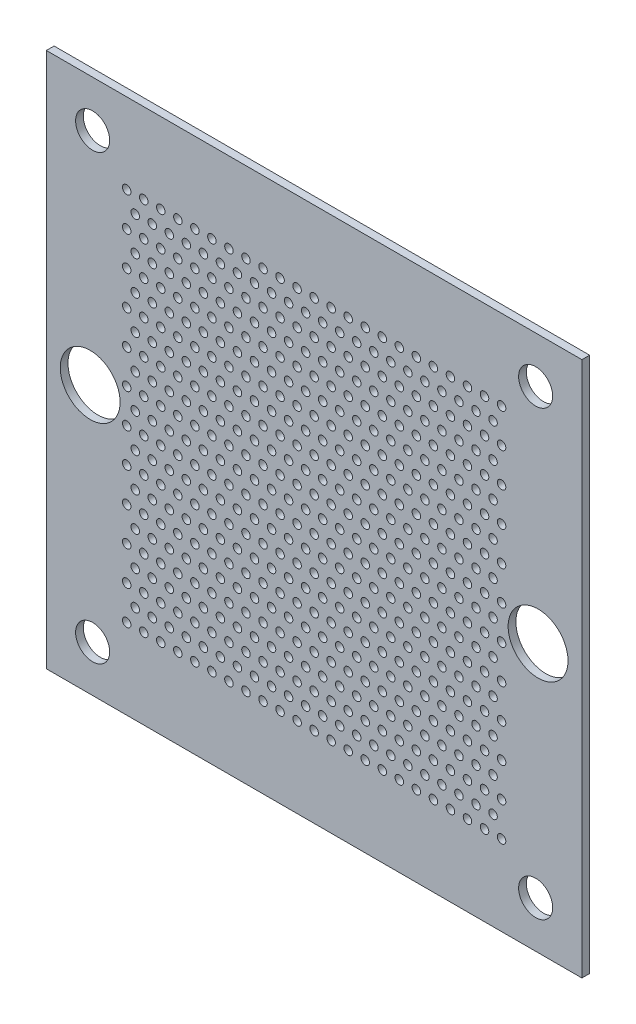
from build123d import *

# Parameters (mm, degrees)
MODEL_W             = 110
MODEL_H             = 110
MODEL_R             = 3.5
MODEL_R_2           = 0.875
MODEL_R_3           = 6.15
BOSS_EXTRUDE1_DEPTH = 1.5875


with BuildPart() as part:
    # Model → Boss-Extrude1 (new body)
    with BuildSketch(Plane.XY):
        with Locations((38.5, 38.5)):
            Rectangle(MODEL_W, MODEL_H)
        with Locations((84, 84)):
            Circle(MODEL_R, mode=Mode.SUBTRACT)
        with Locations((-7, 84)):
            Circle(MODEL_R, mode=Mode.SUBTRACT)
        with Locations((-7, -7)):
            Circle(MODEL_R, mode=Mode.SUBTRACT)
        with Locations((84, -7)):
            Circle(MODEL_R, mode=Mode.SUBTRACT)
        with Locations((77, 0)):
            Circle(MODEL_R_2, mode=Mode.SUBTRACT)
        with Locations((73.5, 0)):
            Circle(MODEL_R_2, mode=Mode.SUBTRACT)
        with Locations((70, 0)):
            Circle(MODEL_R_2, mode=Mode.SUBTRACT)
        with Locations((66.5, 0)):
            Circle(MODEL_R_2, mode=Mode.SUBTRACT)
        with Locations((63, 0)):
            Circle(MODEL_R_2, mode=Mode.SUBTRACT)
        with Locations((59.5, 0)):
            Circle(MODEL_R_2, mode=Mode.SUBTRACT)
        with Locations((56, 0)):
            Circle(MODEL_R_2, mode=Mode.SUBTRACT)
        with Locations((52.5, 0)):
            Circle(MODEL_R_2, mode=Mode.SUBTRACT)
        with Locations((49, 0)):
            Circle(MODEL_R_2, mode=Mode.SUBTRACT)
        with Locations((45.5, 0)):
            Circle(MODEL_R_2, mode=Mode.SUBTRACT)
        with Locations((42, 0)):
            Circle(MODEL_R_2, mode=Mode.SUBTRACT)
        with Locations((38.5, 0)):
            Circle(MODEL_R_2, mode=Mode.SUBTRACT)
        with Locations((35, 0)):
            Circle(MODEL_R_2, mode=Mode.SUBTRACT)
        with Locations((31.5, 0)):
            Circle(MODEL_R_2, mode=Mode.SUBTRACT)
        with Locations((28, 0)):
            Circle(MODEL_R_2, mode=Mode.SUBTRACT)
        with Locations((24.5, 0)):
            Circle(MODEL_R_2, mode=Mode.SUBTRACT)
        with Locations((21, 0)):
            Circle(MODEL_R_2, mode=Mode.SUBTRACT)
        with Locations((17.5, 0)):
            Circle(MODEL_R_2, mode=Mode.SUBTRACT)
        with Locations((14, 0)):
            Circle(MODEL_R_2, mode=Mode.SUBTRACT)
        with Locations((10.5, 0)):
            Circle(MODEL_R_2, mode=Mode.SUBTRACT)
        with Locations((7, 0)):
            Circle(MODEL_R_2, mode=Mode.SUBTRACT)
        with Locations((3.5, 0)):
            Circle(MODEL_R_2, mode=Mode.SUBTRACT)
        Circle(MODEL_R_2, mode=Mode.SUBTRACT)
        with Locations((75.25, 3.5)):
            Circle(MODEL_R_2, mode=Mode.SUBTRACT)
        with Locations((71.75, 3.5)):
            Circle(MODEL_R_2, mode=Mode.SUBTRACT)
        with Locations((68.25, 3.5)):
            Circle(MODEL_R_2, mode=Mode.SUBTRACT)
        with Locations((64.75, 3.5)):
            Circle(MODEL_R_2, mode=Mode.SUBTRACT)
        with Locations((61.25, 3.5)):
            Circle(MODEL_R_2, mode=Mode.SUBTRACT)
        with Locations((57.75, 3.5)):
            Circle(MODEL_R_2, mode=Mode.SUBTRACT)
        with Locations((54.25, 3.5)):
            Circle(MODEL_R_2, mode=Mode.SUBTRACT)
        with Locations((50.75, 3.5)):
            Circle(MODEL_R_2, mode=Mode.SUBTRACT)
        with Locations((47.25, 3.5)):
            Circle(MODEL_R_2, mode=Mode.SUBTRACT)
        with Locations((43.75, 3.5)):
            Circle(MODEL_R_2, mode=Mode.SUBTRACT)
        with Locations((40.25, 3.5)):
            Circle(MODEL_R_2, mode=Mode.SUBTRACT)
        with Locations((36.75, 3.5)):
            Circle(MODEL_R_2, mode=Mode.SUBTRACT)
        with Locations((33.25, 3.5)):
            Circle(MODEL_R_2, mode=Mode.SUBTRACT)
        with Locations((29.75, 3.5)):
            Circle(MODEL_R_2, mode=Mode.SUBTRACT)
        with Locations((26.25, 3.5)):
            Circle(MODEL_R_2, mode=Mode.SUBTRACT)
        with Locations((22.75, 3.5)):
            Circle(MODEL_R_2, mode=Mode.SUBTRACT)
        with Locations((19.25, 3.5)):
            Circle(MODEL_R_2, mode=Mode.SUBTRACT)
        with Locations((15.75, 3.5)):
            Circle(MODEL_R_2, mode=Mode.SUBTRACT)
        with Locations((12.25, 3.5)):
            Circle(MODEL_R_2, mode=Mode.SUBTRACT)
        with Locations((8.75, 3.5)):
            Circle(MODEL_R_2, mode=Mode.SUBTRACT)
        with Locations((5.25, 3.5)):
            Circle(MODEL_R_2, mode=Mode.SUBTRACT)
        with Locations((1.75, 3.5)):
            Circle(MODEL_R_2, mode=Mode.SUBTRACT)
        with Locations((77, 7)):
            Circle(MODEL_R_2, mode=Mode.SUBTRACT)
        with Locations((73.5, 7)):
            Circle(MODEL_R_2, mode=Mode.SUBTRACT)
        with Locations((70, 7)):
            Circle(MODEL_R_2, mode=Mode.SUBTRACT)
        with Locations((66.5, 7)):
            Circle(MODEL_R_2, mode=Mode.SUBTRACT)
        with Locations((63, 7)):
            Circle(MODEL_R_2, mode=Mode.SUBTRACT)
        with Locations((59.5, 7)):
            Circle(MODEL_R_2, mode=Mode.SUBTRACT)
        with Locations((56, 7)):
            Circle(MODEL_R_2, mode=Mode.SUBTRACT)
        with Locations((52.5, 7)):
            Circle(MODEL_R_2, mode=Mode.SUBTRACT)
        with Locations((49, 7)):
            Circle(MODEL_R_2, mode=Mode.SUBTRACT)
        with Locations((45.5, 7)):
            Circle(MODEL_R_2, mode=Mode.SUBTRACT)
        with Locations((42, 7)):
            Circle(MODEL_R_2, mode=Mode.SUBTRACT)
        with Locations((38.5, 7)):
            Circle(MODEL_R_2, mode=Mode.SUBTRACT)
        with Locations((35, 7)):
            Circle(MODEL_R_2, mode=Mode.SUBTRACT)
        with Locations((31.5, 7)):
            Circle(MODEL_R_2, mode=Mode.SUBTRACT)
        with Locations((28, 7)):
            Circle(MODEL_R_2, mode=Mode.SUBTRACT)
        with Locations((24.5, 7)):
            Circle(MODEL_R_2, mode=Mode.SUBTRACT)
        with Locations((21, 7)):
            Circle(MODEL_R_2, mode=Mode.SUBTRACT)
        with Locations((17.5, 7)):
            Circle(MODEL_R_2, mode=Mode.SUBTRACT)
        with Locations((14, 7)):
            Circle(MODEL_R_2, mode=Mode.SUBTRACT)
        with Locations((10.5, 7)):
            Circle(MODEL_R_2, mode=Mode.SUBTRACT)
        with Locations((7, 7)):
            Circle(MODEL_R_2, mode=Mode.SUBTRACT)
        with Locations((3.5, 7)):
            Circle(MODEL_R_2, mode=Mode.SUBTRACT)
        with Locations((0, 7)):
            Circle(MODEL_R_2, mode=Mode.SUBTRACT)
        with Locations((75.25, 10.5)):
            Circle(MODEL_R_2, mode=Mode.SUBTRACT)
        with Locations((71.75, 10.5)):
            Circle(MODEL_R_2, mode=Mode.SUBTRACT)
        with Locations((68.25, 10.5)):
            Circle(MODEL_R_2, mode=Mode.SUBTRACT)
        with Locations((64.75, 10.5)):
            Circle(MODEL_R_2, mode=Mode.SUBTRACT)
        with Locations((61.25, 10.5)):
            Circle(MODEL_R_2, mode=Mode.SUBTRACT)
        with Locations((57.75, 10.5)):
            Circle(MODEL_R_2, mode=Mode.SUBTRACT)
        with Locations((54.25, 10.5)):
            Circle(MODEL_R_2, mode=Mode.SUBTRACT)
        with Locations((50.75, 10.5)):
            Circle(MODEL_R_2, mode=Mode.SUBTRACT)
        with Locations((47.25, 10.5)):
            Circle(MODEL_R_2, mode=Mode.SUBTRACT)
        with Locations((43.75, 10.5)):
            Circle(MODEL_R_2, mode=Mode.SUBTRACT)
        with Locations((40.25, 10.5)):
            Circle(MODEL_R_2, mode=Mode.SUBTRACT)
        with Locations((36.75, 10.5)):
            Circle(MODEL_R_2, mode=Mode.SUBTRACT)
        with Locations((33.25, 10.5)):
            Circle(MODEL_R_2, mode=Mode.SUBTRACT)
        with Locations((29.75, 10.5)):
            Circle(MODEL_R_2, mode=Mode.SUBTRACT)
        with Locations((26.25, 10.5)):
            Circle(MODEL_R_2, mode=Mode.SUBTRACT)
        with Locations((22.75, 10.5)):
            Circle(MODEL_R_2, mode=Mode.SUBTRACT)
        with Locations((19.25, 10.5)):
            Circle(MODEL_R_2, mode=Mode.SUBTRACT)
        with Locations((15.75, 10.5)):
            Circle(MODEL_R_2, mode=Mode.SUBTRACT)
        with Locations((12.25, 10.5)):
            Circle(MODEL_R_2, mode=Mode.SUBTRACT)
        with Locations((8.75, 10.5)):
            Circle(MODEL_R_2, mode=Mode.SUBTRACT)
        with Locations((5.25, 10.5)):
            Circle(MODEL_R_2, mode=Mode.SUBTRACT)
        with Locations((1.75, 10.5)):
            Circle(MODEL_R_2, mode=Mode.SUBTRACT)
        with Locations((77, 14)):
            Circle(MODEL_R_2, mode=Mode.SUBTRACT)
        with Locations((73.5, 14)):
            Circle(MODEL_R_2, mode=Mode.SUBTRACT)
        with Locations((70, 14)):
            Circle(MODEL_R_2, mode=Mode.SUBTRACT)
        with Locations((66.5, 14)):
            Circle(MODEL_R_2, mode=Mode.SUBTRACT)
        with Locations((63, 14)):
            Circle(MODEL_R_2, mode=Mode.SUBTRACT)
        with Locations((59.5, 14)):
            Circle(MODEL_R_2, mode=Mode.SUBTRACT)
        with Locations((56, 14)):
            Circle(MODEL_R_2, mode=Mode.SUBTRACT)
        with Locations((52.5, 14)):
            Circle(MODEL_R_2, mode=Mode.SUBTRACT)
        with Locations((49, 14)):
            Circle(MODEL_R_2, mode=Mode.SUBTRACT)
        with Locations((45.5, 14)):
            Circle(MODEL_R_2, mode=Mode.SUBTRACT)
        with Locations((42, 14)):
            Circle(MODEL_R_2, mode=Mode.SUBTRACT)
        with Locations((38.5, 14)):
            Circle(MODEL_R_2, mode=Mode.SUBTRACT)
        with Locations((35, 14)):
            Circle(MODEL_R_2, mode=Mode.SUBTRACT)
        with Locations((31.5, 14)):
            Circle(MODEL_R_2, mode=Mode.SUBTRACT)
        with Locations((28, 14)):
            Circle(MODEL_R_2, mode=Mode.SUBTRACT)
        with Locations((24.5, 14)):
            Circle(MODEL_R_2, mode=Mode.SUBTRACT)
        with Locations((21, 14)):
            Circle(MODEL_R_2, mode=Mode.SUBTRACT)
        with Locations((17.5, 14)):
            Circle(MODEL_R_2, mode=Mode.SUBTRACT)
        with Locations((14, 14)):
            Circle(MODEL_R_2, mode=Mode.SUBTRACT)
        with Locations((10.5, 14)):
            Circle(MODEL_R_2, mode=Mode.SUBTRACT)
        with Locations((7, 14)):
            Circle(MODEL_R_2, mode=Mode.SUBTRACT)
        with Locations((3.5, 14)):
            Circle(MODEL_R_2, mode=Mode.SUBTRACT)
        with Locations((0, 14)):
            Circle(MODEL_R_2, mode=Mode.SUBTRACT)
        with Locations((75.25, 17.5)):
            Circle(MODEL_R_2, mode=Mode.SUBTRACT)
        with Locations((71.75, 17.5)):
            Circle(MODEL_R_2, mode=Mode.SUBTRACT)
        with Locations((68.25, 17.5)):
            Circle(MODEL_R_2, mode=Mode.SUBTRACT)
        with Locations((64.75, 17.5)):
            Circle(MODEL_R_2, mode=Mode.SUBTRACT)
        with Locations((61.25, 17.5)):
            Circle(MODEL_R_2, mode=Mode.SUBTRACT)
        with Locations((57.75, 17.5)):
            Circle(MODEL_R_2, mode=Mode.SUBTRACT)
        with Locations((54.25, 17.5)):
            Circle(MODEL_R_2, mode=Mode.SUBTRACT)
        with Locations((50.75, 17.5)):
            Circle(MODEL_R_2, mode=Mode.SUBTRACT)
        with Locations((47.25, 17.5)):
            Circle(MODEL_R_2, mode=Mode.SUBTRACT)
        with Locations((43.75, 17.5)):
            Circle(MODEL_R_2, mode=Mode.SUBTRACT)
        with Locations((40.25, 17.5)):
            Circle(MODEL_R_2, mode=Mode.SUBTRACT)
        with Locations((36.75, 17.5)):
            Circle(MODEL_R_2, mode=Mode.SUBTRACT)
        with Locations((33.25, 17.5)):
            Circle(MODEL_R_2, mode=Mode.SUBTRACT)
        with Locations((29.75, 17.5)):
            Circle(MODEL_R_2, mode=Mode.SUBTRACT)
        with Locations((26.25, 17.5)):
            Circle(MODEL_R_2, mode=Mode.SUBTRACT)
        with Locations((22.75, 17.5)):
            Circle(MODEL_R_2, mode=Mode.SUBTRACT)
        with Locations((19.25, 17.5)):
            Circle(MODEL_R_2, mode=Mode.SUBTRACT)
        with Locations((15.75, 17.5)):
            Circle(MODEL_R_2, mode=Mode.SUBTRACT)
        with Locations((12.25, 17.5)):
            Circle(MODEL_R_2, mode=Mode.SUBTRACT)
        with Locations((8.75, 17.5)):
            Circle(MODEL_R_2, mode=Mode.SUBTRACT)
        with Locations((5.25, 17.5)):
            Circle(MODEL_R_2, mode=Mode.SUBTRACT)
        with Locations((1.75, 17.5)):
            Circle(MODEL_R_2, mode=Mode.SUBTRACT)
        with Locations((77, 21)):
            Circle(MODEL_R_2, mode=Mode.SUBTRACT)
        with Locations((73.5, 21)):
            Circle(MODEL_R_2, mode=Mode.SUBTRACT)
        with Locations((70, 21)):
            Circle(MODEL_R_2, mode=Mode.SUBTRACT)
        with Locations((66.5, 21)):
            Circle(MODEL_R_2, mode=Mode.SUBTRACT)
        with Locations((63, 21)):
            Circle(MODEL_R_2, mode=Mode.SUBTRACT)
        with Locations((59.5, 21)):
            Circle(MODEL_R_2, mode=Mode.SUBTRACT)
        with Locations((56, 21)):
            Circle(MODEL_R_2, mode=Mode.SUBTRACT)
        with Locations((52.5, 21)):
            Circle(MODEL_R_2, mode=Mode.SUBTRACT)
        with Locations((49, 21)):
            Circle(MODEL_R_2, mode=Mode.SUBTRACT)
        with Locations((45.5, 21)):
            Circle(MODEL_R_2, mode=Mode.SUBTRACT)
        with Locations((42, 21)):
            Circle(MODEL_R_2, mode=Mode.SUBTRACT)
        with Locations((38.5, 21)):
            Circle(MODEL_R_2, mode=Mode.SUBTRACT)
        with Locations((35, 21)):
            Circle(MODEL_R_2, mode=Mode.SUBTRACT)
        with Locations((31.5, 21)):
            Circle(MODEL_R_2, mode=Mode.SUBTRACT)
        with Locations((28, 21)):
            Circle(MODEL_R_2, mode=Mode.SUBTRACT)
        with Locations((24.5, 21)):
            Circle(MODEL_R_2, mode=Mode.SUBTRACT)
        with Locations((21, 21)):
            Circle(MODEL_R_2, mode=Mode.SUBTRACT)
        with Locations((17.5, 21)):
            Circle(MODEL_R_2, mode=Mode.SUBTRACT)
        with Locations((14, 21)):
            Circle(MODEL_R_2, mode=Mode.SUBTRACT)
        with Locations((10.5, 21)):
            Circle(MODEL_R_2, mode=Mode.SUBTRACT)
        with Locations((7, 21)):
            Circle(MODEL_R_2, mode=Mode.SUBTRACT)
        with Locations((3.5, 21)):
            Circle(MODEL_R_2, mode=Mode.SUBTRACT)
        with Locations((0, 21)):
            Circle(MODEL_R_2, mode=Mode.SUBTRACT)
        with Locations((75.25, 24.5)):
            Circle(MODEL_R_2, mode=Mode.SUBTRACT)
        with Locations((71.75, 24.5)):
            Circle(MODEL_R_2, mode=Mode.SUBTRACT)
        with Locations((68.25, 24.5)):
            Circle(MODEL_R_2, mode=Mode.SUBTRACT)
        with Locations((64.75, 24.5)):
            Circle(MODEL_R_2, mode=Mode.SUBTRACT)
        with Locations((61.25, 24.5)):
            Circle(MODEL_R_2, mode=Mode.SUBTRACT)
        with Locations((57.75, 24.5)):
            Circle(MODEL_R_2, mode=Mode.SUBTRACT)
        with Locations((54.25, 24.5)):
            Circle(MODEL_R_2, mode=Mode.SUBTRACT)
        with Locations((50.75, 24.5)):
            Circle(MODEL_R_2, mode=Mode.SUBTRACT)
        with Locations((47.25, 24.5)):
            Circle(MODEL_R_2, mode=Mode.SUBTRACT)
        with Locations((43.75, 24.5)):
            Circle(MODEL_R_2, mode=Mode.SUBTRACT)
        with Locations((40.25, 24.5)):
            Circle(MODEL_R_2, mode=Mode.SUBTRACT)
        with Locations((36.75, 24.5)):
            Circle(MODEL_R_2, mode=Mode.SUBTRACT)
        with Locations((33.25, 24.5)):
            Circle(MODEL_R_2, mode=Mode.SUBTRACT)
        with Locations((29.75, 24.5)):
            Circle(MODEL_R_2, mode=Mode.SUBTRACT)
        with Locations((26.25, 24.5)):
            Circle(MODEL_R_2, mode=Mode.SUBTRACT)
        with Locations((22.75, 24.5)):
            Circle(MODEL_R_2, mode=Mode.SUBTRACT)
        with Locations((19.25, 24.5)):
            Circle(MODEL_R_2, mode=Mode.SUBTRACT)
        with Locations((15.75, 24.5)):
            Circle(MODEL_R_2, mode=Mode.SUBTRACT)
        with Locations((12.25, 24.5)):
            Circle(MODEL_R_2, mode=Mode.SUBTRACT)
        with Locations((8.75, 24.5)):
            Circle(MODEL_R_2, mode=Mode.SUBTRACT)
        with Locations((5.25, 24.5)):
            Circle(MODEL_R_2, mode=Mode.SUBTRACT)
        with Locations((1.75, 24.5)):
            Circle(MODEL_R_2, mode=Mode.SUBTRACT)
        with Locations((77, 28)):
            Circle(MODEL_R_2, mode=Mode.SUBTRACT)
        with Locations((73.5, 28)):
            Circle(MODEL_R_2, mode=Mode.SUBTRACT)
        with Locations((70, 28)):
            Circle(MODEL_R_2, mode=Mode.SUBTRACT)
        with Locations((66.5, 28)):
            Circle(MODEL_R_2, mode=Mode.SUBTRACT)
        with Locations((63, 28)):
            Circle(MODEL_R_2, mode=Mode.SUBTRACT)
        with Locations((59.5, 28)):
            Circle(MODEL_R_2, mode=Mode.SUBTRACT)
        with Locations((56, 28)):
            Circle(MODEL_R_2, mode=Mode.SUBTRACT)
        with Locations((52.5, 28)):
            Circle(MODEL_R_2, mode=Mode.SUBTRACT)
        with Locations((49, 28)):
            Circle(MODEL_R_2, mode=Mode.SUBTRACT)
        with Locations((45.5, 28)):
            Circle(MODEL_R_2, mode=Mode.SUBTRACT)
        with Locations((42, 28)):
            Circle(MODEL_R_2, mode=Mode.SUBTRACT)
        with Locations((38.5, 28)):
            Circle(MODEL_R_2, mode=Mode.SUBTRACT)
        with Locations((35, 28)):
            Circle(MODEL_R_2, mode=Mode.SUBTRACT)
        with Locations((31.5, 28)):
            Circle(MODEL_R_2, mode=Mode.SUBTRACT)
        with Locations((28, 28)):
            Circle(MODEL_R_2, mode=Mode.SUBTRACT)
        with Locations((24.5, 28)):
            Circle(MODEL_R_2, mode=Mode.SUBTRACT)
        with Locations((21, 28)):
            Circle(MODEL_R_2, mode=Mode.SUBTRACT)
        with Locations((17.5, 28)):
            Circle(MODEL_R_2, mode=Mode.SUBTRACT)
        with Locations((14, 28)):
            Circle(MODEL_R_2, mode=Mode.SUBTRACT)
        with Locations((10.5, 28)):
            Circle(MODEL_R_2, mode=Mode.SUBTRACT)
        with Locations((7, 28)):
            Circle(MODEL_R_2, mode=Mode.SUBTRACT)
        with Locations((3.5, 28)):
            Circle(MODEL_R_2, mode=Mode.SUBTRACT)
        with Locations((0, 28)):
            Circle(MODEL_R_2, mode=Mode.SUBTRACT)
        with Locations((75.25, 31.5)):
            Circle(MODEL_R_2, mode=Mode.SUBTRACT)
        with Locations((71.75, 31.5)):
            Circle(MODEL_R_2, mode=Mode.SUBTRACT)
        with Locations((68.25, 31.5)):
            Circle(MODEL_R_2, mode=Mode.SUBTRACT)
        with Locations((64.75, 31.5)):
            Circle(MODEL_R_2, mode=Mode.SUBTRACT)
        with Locations((61.25, 31.5)):
            Circle(MODEL_R_2, mode=Mode.SUBTRACT)
        with Locations((57.75, 31.5)):
            Circle(MODEL_R_2, mode=Mode.SUBTRACT)
        with Locations((54.25, 31.5)):
            Circle(MODEL_R_2, mode=Mode.SUBTRACT)
        with Locations((50.75, 31.5)):
            Circle(MODEL_R_2, mode=Mode.SUBTRACT)
        with Locations((47.25, 31.5)):
            Circle(MODEL_R_2, mode=Mode.SUBTRACT)
        with Locations((43.75, 31.5)):
            Circle(MODEL_R_2, mode=Mode.SUBTRACT)
        with Locations((40.25, 31.5)):
            Circle(MODEL_R_2, mode=Mode.SUBTRACT)
        with Locations((36.75, 31.5)):
            Circle(MODEL_R_2, mode=Mode.SUBTRACT)
        with Locations((33.25, 31.5)):
            Circle(MODEL_R_2, mode=Mode.SUBTRACT)
        with Locations((29.75, 31.5)):
            Circle(MODEL_R_2, mode=Mode.SUBTRACT)
        with Locations((26.25, 31.5)):
            Circle(MODEL_R_2, mode=Mode.SUBTRACT)
        with Locations((22.75, 31.5)):
            Circle(MODEL_R_2, mode=Mode.SUBTRACT)
        with Locations((19.25, 31.5)):
            Circle(MODEL_R_2, mode=Mode.SUBTRACT)
        with Locations((15.75, 31.5)):
            Circle(MODEL_R_2, mode=Mode.SUBTRACT)
        with Locations((12.25, 31.5)):
            Circle(MODEL_R_2, mode=Mode.SUBTRACT)
        with Locations((8.75, 31.5)):
            Circle(MODEL_R_2, mode=Mode.SUBTRACT)
        with Locations((5.25, 31.5)):
            Circle(MODEL_R_2, mode=Mode.SUBTRACT)
        with Locations((1.75, 31.5)):
            Circle(MODEL_R_2, mode=Mode.SUBTRACT)
        with Locations((77, 35)):
            Circle(MODEL_R_2, mode=Mode.SUBTRACT)
        with Locations((73.5, 35)):
            Circle(MODEL_R_2, mode=Mode.SUBTRACT)
        with Locations((70, 35)):
            Circle(MODEL_R_2, mode=Mode.SUBTRACT)
        with Locations((66.5, 35)):
            Circle(MODEL_R_2, mode=Mode.SUBTRACT)
        with Locations((63, 35)):
            Circle(MODEL_R_2, mode=Mode.SUBTRACT)
        with Locations((59.5, 35)):
            Circle(MODEL_R_2, mode=Mode.SUBTRACT)
        with Locations((56, 35)):
            Circle(MODEL_R_2, mode=Mode.SUBTRACT)
        with Locations((52.5, 35)):
            Circle(MODEL_R_2, mode=Mode.SUBTRACT)
        with Locations((49, 35)):
            Circle(MODEL_R_2, mode=Mode.SUBTRACT)
        with Locations((45.5, 35)):
            Circle(MODEL_R_2, mode=Mode.SUBTRACT)
        with Locations((42, 35)):
            Circle(MODEL_R_2, mode=Mode.SUBTRACT)
        with Locations((38.5, 35)):
            Circle(MODEL_R_2, mode=Mode.SUBTRACT)
        with Locations((35, 35)):
            Circle(MODEL_R_2, mode=Mode.SUBTRACT)
        with Locations((31.5, 35)):
            Circle(MODEL_R_2, mode=Mode.SUBTRACT)
        with Locations((28, 35)):
            Circle(MODEL_R_2, mode=Mode.SUBTRACT)
        with Locations((24.5, 35)):
            Circle(MODEL_R_2, mode=Mode.SUBTRACT)
        with Locations((21, 35)):
            Circle(MODEL_R_2, mode=Mode.SUBTRACT)
        with Locations((17.5, 35)):
            Circle(MODEL_R_2, mode=Mode.SUBTRACT)
        with Locations((14, 35)):
            Circle(MODEL_R_2, mode=Mode.SUBTRACT)
        with Locations((10.5, 35)):
            Circle(MODEL_R_2, mode=Mode.SUBTRACT)
        with Locations((7, 35)):
            Circle(MODEL_R_2, mode=Mode.SUBTRACT)
        with Locations((3.5, 35)):
            Circle(MODEL_R_2, mode=Mode.SUBTRACT)
        with Locations((0, 35)):
            Circle(MODEL_R_2, mode=Mode.SUBTRACT)
        with Locations((75.25, 38.5)):
            Circle(MODEL_R_2, mode=Mode.SUBTRACT)
        with Locations((71.75, 38.5)):
            Circle(MODEL_R_2, mode=Mode.SUBTRACT)
        with Locations((68.25, 38.5)):
            Circle(MODEL_R_2, mode=Mode.SUBTRACT)
        with Locations((64.75, 38.5)):
            Circle(MODEL_R_2, mode=Mode.SUBTRACT)
        with Locations((61.25, 38.5)):
            Circle(MODEL_R_2, mode=Mode.SUBTRACT)
        with Locations((57.75, 38.5)):
            Circle(MODEL_R_2, mode=Mode.SUBTRACT)
        with Locations((54.25, 38.5)):
            Circle(MODEL_R_2, mode=Mode.SUBTRACT)
        with Locations((50.75, 38.5)):
            Circle(MODEL_R_2, mode=Mode.SUBTRACT)
        with Locations((47.25, 38.5)):
            Circle(MODEL_R_2, mode=Mode.SUBTRACT)
        with Locations((43.75, 38.5)):
            Circle(MODEL_R_2, mode=Mode.SUBTRACT)
        with Locations((40.25, 38.5)):
            Circle(MODEL_R_2, mode=Mode.SUBTRACT)
        with Locations((36.75, 38.5)):
            Circle(MODEL_R_2, mode=Mode.SUBTRACT)
        with Locations((33.25, 38.5)):
            Circle(MODEL_R_2, mode=Mode.SUBTRACT)
        with Locations((29.75, 38.5)):
            Circle(MODEL_R_2, mode=Mode.SUBTRACT)
        with Locations((26.25, 38.5)):
            Circle(MODEL_R_2, mode=Mode.SUBTRACT)
        with Locations((22.75, 38.5)):
            Circle(MODEL_R_2, mode=Mode.SUBTRACT)
        with Locations((19.25, 38.5)):
            Circle(MODEL_R_2, mode=Mode.SUBTRACT)
        with Locations((15.75, 38.5)):
            Circle(MODEL_R_2, mode=Mode.SUBTRACT)
        with Locations((12.25, 38.5)):
            Circle(MODEL_R_2, mode=Mode.SUBTRACT)
        with Locations((8.75, 38.5)):
            Circle(MODEL_R_2, mode=Mode.SUBTRACT)
        with Locations((5.25, 38.5)):
            Circle(MODEL_R_2, mode=Mode.SUBTRACT)
        with Locations((1.75, 38.5)):
            Circle(MODEL_R_2, mode=Mode.SUBTRACT)
        with Locations((77, 42)):
            Circle(MODEL_R_2, mode=Mode.SUBTRACT)
        with Locations((73.5, 42)):
            Circle(MODEL_R_2, mode=Mode.SUBTRACT)
        with Locations((70, 42)):
            Circle(MODEL_R_2, mode=Mode.SUBTRACT)
        with Locations((66.5, 42)):
            Circle(MODEL_R_2, mode=Mode.SUBTRACT)
        with Locations((63, 42)):
            Circle(MODEL_R_2, mode=Mode.SUBTRACT)
        with Locations((59.5, 42)):
            Circle(MODEL_R_2, mode=Mode.SUBTRACT)
        with Locations((56, 42)):
            Circle(MODEL_R_2, mode=Mode.SUBTRACT)
        with Locations((52.5, 42)):
            Circle(MODEL_R_2, mode=Mode.SUBTRACT)
        with Locations((49, 42)):
            Circle(MODEL_R_2, mode=Mode.SUBTRACT)
        with Locations((45.5, 42)):
            Circle(MODEL_R_2, mode=Mode.SUBTRACT)
        with Locations((42, 42)):
            Circle(MODEL_R_2, mode=Mode.SUBTRACT)
        with Locations((38.5, 42)):
            Circle(MODEL_R_2, mode=Mode.SUBTRACT)
        with Locations((35, 42)):
            Circle(MODEL_R_2, mode=Mode.SUBTRACT)
        with Locations((31.5, 42)):
            Circle(MODEL_R_2, mode=Mode.SUBTRACT)
        with Locations((28, 42)):
            Circle(MODEL_R_2, mode=Mode.SUBTRACT)
        with Locations((24.5, 42)):
            Circle(MODEL_R_2, mode=Mode.SUBTRACT)
        with Locations((21, 42)):
            Circle(MODEL_R_2, mode=Mode.SUBTRACT)
        with Locations((17.5, 42)):
            Circle(MODEL_R_2, mode=Mode.SUBTRACT)
        with Locations((14, 42)):
            Circle(MODEL_R_2, mode=Mode.SUBTRACT)
        with Locations((10.5, 42)):
            Circle(MODEL_R_2, mode=Mode.SUBTRACT)
        with Locations((7, 42)):
            Circle(MODEL_R_2, mode=Mode.SUBTRACT)
        with Locations((3.5, 42)):
            Circle(MODEL_R_2, mode=Mode.SUBTRACT)
        with Locations((0, 42)):
            Circle(MODEL_R_2, mode=Mode.SUBTRACT)
        with Locations((75.25, 45.5)):
            Circle(MODEL_R_2, mode=Mode.SUBTRACT)
        with Locations((71.75, 45.5)):
            Circle(MODEL_R_2, mode=Mode.SUBTRACT)
        with Locations((68.25, 45.5)):
            Circle(MODEL_R_2, mode=Mode.SUBTRACT)
        with Locations((64.75, 45.5)):
            Circle(MODEL_R_2, mode=Mode.SUBTRACT)
        with Locations((61.25, 45.5)):
            Circle(MODEL_R_2, mode=Mode.SUBTRACT)
        with Locations((57.75, 45.5)):
            Circle(MODEL_R_2, mode=Mode.SUBTRACT)
        with Locations((54.25, 45.5)):
            Circle(MODEL_R_2, mode=Mode.SUBTRACT)
        with Locations((50.75, 45.5)):
            Circle(MODEL_R_2, mode=Mode.SUBTRACT)
        with Locations((47.25, 45.5)):
            Circle(MODEL_R_2, mode=Mode.SUBTRACT)
        with Locations((43.75, 45.5)):
            Circle(MODEL_R_2, mode=Mode.SUBTRACT)
        with Locations((40.25, 45.5)):
            Circle(MODEL_R_2, mode=Mode.SUBTRACT)
        with Locations((36.75, 45.5)):
            Circle(MODEL_R_2, mode=Mode.SUBTRACT)
        with Locations((33.25, 45.5)):
            Circle(MODEL_R_2, mode=Mode.SUBTRACT)
        with Locations((29.75, 45.5)):
            Circle(MODEL_R_2, mode=Mode.SUBTRACT)
        with Locations((26.25, 45.5)):
            Circle(MODEL_R_2, mode=Mode.SUBTRACT)
        with Locations((22.75, 45.5)):
            Circle(MODEL_R_2, mode=Mode.SUBTRACT)
        with Locations((19.25, 45.5)):
            Circle(MODEL_R_2, mode=Mode.SUBTRACT)
        with Locations((15.75, 45.5)):
            Circle(MODEL_R_2, mode=Mode.SUBTRACT)
        with Locations((12.25, 45.5)):
            Circle(MODEL_R_2, mode=Mode.SUBTRACT)
        with Locations((8.75, 45.5)):
            Circle(MODEL_R_2, mode=Mode.SUBTRACT)
        with Locations((5.25, 45.5)):
            Circle(MODEL_R_2, mode=Mode.SUBTRACT)
        with Locations((1.75, 45.5)):
            Circle(MODEL_R_2, mode=Mode.SUBTRACT)
        with Locations((77, 49)):
            Circle(MODEL_R_2, mode=Mode.SUBTRACT)
        with Locations((73.5, 49)):
            Circle(MODEL_R_2, mode=Mode.SUBTRACT)
        with Locations((70, 49)):
            Circle(MODEL_R_2, mode=Mode.SUBTRACT)
        with Locations((66.5, 49)):
            Circle(MODEL_R_2, mode=Mode.SUBTRACT)
        with Locations((63, 49)):
            Circle(MODEL_R_2, mode=Mode.SUBTRACT)
        with Locations((59.5, 49)):
            Circle(MODEL_R_2, mode=Mode.SUBTRACT)
        with Locations((56, 49)):
            Circle(MODEL_R_2, mode=Mode.SUBTRACT)
        with Locations((52.5, 49)):
            Circle(MODEL_R_2, mode=Mode.SUBTRACT)
        with Locations((49, 49)):
            Circle(MODEL_R_2, mode=Mode.SUBTRACT)
        with Locations((45.5, 49)):
            Circle(MODEL_R_2, mode=Mode.SUBTRACT)
        with Locations((42, 49)):
            Circle(MODEL_R_2, mode=Mode.SUBTRACT)
        with Locations((38.5, 49)):
            Circle(MODEL_R_2, mode=Mode.SUBTRACT)
        with Locations((35, 49)):
            Circle(MODEL_R_2, mode=Mode.SUBTRACT)
        with Locations((31.5, 49)):
            Circle(MODEL_R_2, mode=Mode.SUBTRACT)
        with Locations((28, 49)):
            Circle(MODEL_R_2, mode=Mode.SUBTRACT)
        with Locations((24.5, 49)):
            Circle(MODEL_R_2, mode=Mode.SUBTRACT)
        with Locations((21, 49)):
            Circle(MODEL_R_2, mode=Mode.SUBTRACT)
        with Locations((17.5, 49)):
            Circle(MODEL_R_2, mode=Mode.SUBTRACT)
        with Locations((14, 49)):
            Circle(MODEL_R_2, mode=Mode.SUBTRACT)
        with Locations((10.5, 49)):
            Circle(MODEL_R_2, mode=Mode.SUBTRACT)
        with Locations((7, 49)):
            Circle(MODEL_R_2, mode=Mode.SUBTRACT)
        with Locations((3.5, 49)):
            Circle(MODEL_R_2, mode=Mode.SUBTRACT)
        with Locations((0, 49)):
            Circle(MODEL_R_2, mode=Mode.SUBTRACT)
        with Locations((75.25, 52.5)):
            Circle(MODEL_R_2, mode=Mode.SUBTRACT)
        with Locations((71.75, 52.5)):
            Circle(MODEL_R_2, mode=Mode.SUBTRACT)
        with Locations((68.25, 52.5)):
            Circle(MODEL_R_2, mode=Mode.SUBTRACT)
        with Locations((64.75, 52.5)):
            Circle(MODEL_R_2, mode=Mode.SUBTRACT)
        with Locations((61.25, 52.5)):
            Circle(MODEL_R_2, mode=Mode.SUBTRACT)
        with Locations((57.75, 52.5)):
            Circle(MODEL_R_2, mode=Mode.SUBTRACT)
        with Locations((54.25, 52.5)):
            Circle(MODEL_R_2, mode=Mode.SUBTRACT)
        with Locations((50.75, 52.5)):
            Circle(MODEL_R_2, mode=Mode.SUBTRACT)
        with Locations((47.25, 52.5)):
            Circle(MODEL_R_2, mode=Mode.SUBTRACT)
        with Locations((43.75, 52.5)):
            Circle(MODEL_R_2, mode=Mode.SUBTRACT)
        with Locations((40.25, 52.5)):
            Circle(MODEL_R_2, mode=Mode.SUBTRACT)
        with Locations((36.75, 52.5)):
            Circle(MODEL_R_2, mode=Mode.SUBTRACT)
        with Locations((33.25, 52.5)):
            Circle(MODEL_R_2, mode=Mode.SUBTRACT)
        with Locations((29.75, 52.5)):
            Circle(MODEL_R_2, mode=Mode.SUBTRACT)
        with Locations((26.25, 52.5)):
            Circle(MODEL_R_2, mode=Mode.SUBTRACT)
        with Locations((22.75, 52.5)):
            Circle(MODEL_R_2, mode=Mode.SUBTRACT)
        with Locations((19.25, 52.5)):
            Circle(MODEL_R_2, mode=Mode.SUBTRACT)
        with Locations((15.75, 52.5)):
            Circle(MODEL_R_2, mode=Mode.SUBTRACT)
        with Locations((12.25, 52.5)):
            Circle(MODEL_R_2, mode=Mode.SUBTRACT)
        with Locations((8.75, 52.5)):
            Circle(MODEL_R_2, mode=Mode.SUBTRACT)
        with Locations((5.25, 52.5)):
            Circle(MODEL_R_2, mode=Mode.SUBTRACT)
        with Locations((1.75, 52.5)):
            Circle(MODEL_R_2, mode=Mode.SUBTRACT)
        with Locations((77, 56)):
            Circle(MODEL_R_2, mode=Mode.SUBTRACT)
        with Locations((73.5, 56)):
            Circle(MODEL_R_2, mode=Mode.SUBTRACT)
        with Locations((70, 56)):
            Circle(MODEL_R_2, mode=Mode.SUBTRACT)
        with Locations((66.5, 56)):
            Circle(MODEL_R_2, mode=Mode.SUBTRACT)
        with Locations((63, 56)):
            Circle(MODEL_R_2, mode=Mode.SUBTRACT)
        with Locations((59.5, 56)):
            Circle(MODEL_R_2, mode=Mode.SUBTRACT)
        with Locations((56, 56)):
            Circle(MODEL_R_2, mode=Mode.SUBTRACT)
        with Locations((52.5, 56)):
            Circle(MODEL_R_2, mode=Mode.SUBTRACT)
        with Locations((49, 56)):
            Circle(MODEL_R_2, mode=Mode.SUBTRACT)
        with Locations((45.5, 56)):
            Circle(MODEL_R_2, mode=Mode.SUBTRACT)
        with Locations((42, 56)):
            Circle(MODEL_R_2, mode=Mode.SUBTRACT)
        with Locations((38.5, 56)):
            Circle(MODEL_R_2, mode=Mode.SUBTRACT)
        with Locations((35, 56)):
            Circle(MODEL_R_2, mode=Mode.SUBTRACT)
        with Locations((31.5, 56)):
            Circle(MODEL_R_2, mode=Mode.SUBTRACT)
        with Locations((28, 56)):
            Circle(MODEL_R_2, mode=Mode.SUBTRACT)
        with Locations((24.5, 56)):
            Circle(MODEL_R_2, mode=Mode.SUBTRACT)
        with Locations((21, 56)):
            Circle(MODEL_R_2, mode=Mode.SUBTRACT)
        with Locations((17.5, 56)):
            Circle(MODEL_R_2, mode=Mode.SUBTRACT)
        with Locations((14, 56)):
            Circle(MODEL_R_2, mode=Mode.SUBTRACT)
        with Locations((10.5, 56)):
            Circle(MODEL_R_2, mode=Mode.SUBTRACT)
        with Locations((7, 56)):
            Circle(MODEL_R_2, mode=Mode.SUBTRACT)
        with Locations((3.5, 56)):
            Circle(MODEL_R_2, mode=Mode.SUBTRACT)
        with Locations((0, 56)):
            Circle(MODEL_R_2, mode=Mode.SUBTRACT)
        with Locations((75.25, 59.5)):
            Circle(MODEL_R_2, mode=Mode.SUBTRACT)
        with Locations((71.75, 59.5)):
            Circle(MODEL_R_2, mode=Mode.SUBTRACT)
        with Locations((68.25, 59.5)):
            Circle(MODEL_R_2, mode=Mode.SUBTRACT)
        with Locations((64.75, 59.5)):
            Circle(MODEL_R_2, mode=Mode.SUBTRACT)
        with Locations((61.25, 59.5)):
            Circle(MODEL_R_2, mode=Mode.SUBTRACT)
        with Locations((57.75, 59.5)):
            Circle(MODEL_R_2, mode=Mode.SUBTRACT)
        with Locations((54.25, 59.5)):
            Circle(MODEL_R_2, mode=Mode.SUBTRACT)
        with Locations((50.75, 59.5)):
            Circle(MODEL_R_2, mode=Mode.SUBTRACT)
        with Locations((47.25, 59.5)):
            Circle(MODEL_R_2, mode=Mode.SUBTRACT)
        with Locations((43.75, 59.5)):
            Circle(MODEL_R_2, mode=Mode.SUBTRACT)
        with Locations((40.25, 59.5)):
            Circle(MODEL_R_2, mode=Mode.SUBTRACT)
        with Locations((36.75, 59.5)):
            Circle(MODEL_R_2, mode=Mode.SUBTRACT)
        with Locations((33.25, 59.5)):
            Circle(MODEL_R_2, mode=Mode.SUBTRACT)
        with Locations((29.75, 59.5)):
            Circle(MODEL_R_2, mode=Mode.SUBTRACT)
        with Locations((26.25, 59.5)):
            Circle(MODEL_R_2, mode=Mode.SUBTRACT)
        with Locations((22.75, 59.5)):
            Circle(MODEL_R_2, mode=Mode.SUBTRACT)
        with Locations((19.25, 59.5)):
            Circle(MODEL_R_2, mode=Mode.SUBTRACT)
        with Locations((15.75, 59.5)):
            Circle(MODEL_R_2, mode=Mode.SUBTRACT)
        with Locations((12.25, 59.5)):
            Circle(MODEL_R_2, mode=Mode.SUBTRACT)
        with Locations((8.75, 59.5)):
            Circle(MODEL_R_2, mode=Mode.SUBTRACT)
        with Locations((5.25, 59.5)):
            Circle(MODEL_R_2, mode=Mode.SUBTRACT)
        with Locations((1.75, 59.5)):
            Circle(MODEL_R_2, mode=Mode.SUBTRACT)
        with Locations((77, 63)):
            Circle(MODEL_R_2, mode=Mode.SUBTRACT)
        with Locations((73.5, 63)):
            Circle(MODEL_R_2, mode=Mode.SUBTRACT)
        with Locations((70, 63)):
            Circle(MODEL_R_2, mode=Mode.SUBTRACT)
        with Locations((66.5, 63)):
            Circle(MODEL_R_2, mode=Mode.SUBTRACT)
        with Locations((63, 63)):
            Circle(MODEL_R_2, mode=Mode.SUBTRACT)
        with Locations((59.5, 63)):
            Circle(MODEL_R_2, mode=Mode.SUBTRACT)
        with Locations((56, 63)):
            Circle(MODEL_R_2, mode=Mode.SUBTRACT)
        with Locations((52.5, 63)):
            Circle(MODEL_R_2, mode=Mode.SUBTRACT)
        with Locations((49, 63)):
            Circle(MODEL_R_2, mode=Mode.SUBTRACT)
        with Locations((45.5, 63)):
            Circle(MODEL_R_2, mode=Mode.SUBTRACT)
        with Locations((42, 63)):
            Circle(MODEL_R_2, mode=Mode.SUBTRACT)
        with Locations((38.5, 63)):
            Circle(MODEL_R_2, mode=Mode.SUBTRACT)
        with Locations((35, 63)):
            Circle(MODEL_R_2, mode=Mode.SUBTRACT)
        with Locations((31.5, 63)):
            Circle(MODEL_R_2, mode=Mode.SUBTRACT)
        with Locations((28, 63)):
            Circle(MODEL_R_2, mode=Mode.SUBTRACT)
        with Locations((24.5, 63)):
            Circle(MODEL_R_2, mode=Mode.SUBTRACT)
        with Locations((21, 63)):
            Circle(MODEL_R_2, mode=Mode.SUBTRACT)
        with Locations((17.5, 63)):
            Circle(MODEL_R_2, mode=Mode.SUBTRACT)
        with Locations((14, 63)):
            Circle(MODEL_R_2, mode=Mode.SUBTRACT)
        with Locations((10.5, 63)):
            Circle(MODEL_R_2, mode=Mode.SUBTRACT)
        with Locations((7, 63)):
            Circle(MODEL_R_2, mode=Mode.SUBTRACT)
        with Locations((3.5, 63)):
            Circle(MODEL_R_2, mode=Mode.SUBTRACT)
        with Locations((0, 63)):
            Circle(MODEL_R_2, mode=Mode.SUBTRACT)
        with Locations((75.25, 66.5)):
            Circle(MODEL_R_2, mode=Mode.SUBTRACT)
        with Locations((71.75, 66.5)):
            Circle(MODEL_R_2, mode=Mode.SUBTRACT)
        with Locations((68.25, 66.5)):
            Circle(MODEL_R_2, mode=Mode.SUBTRACT)
        with Locations((64.75, 66.5)):
            Circle(MODEL_R_2, mode=Mode.SUBTRACT)
        with Locations((61.25, 66.5)):
            Circle(MODEL_R_2, mode=Mode.SUBTRACT)
        with Locations((57.75, 66.5)):
            Circle(MODEL_R_2, mode=Mode.SUBTRACT)
        with Locations((54.25, 66.5)):
            Circle(MODEL_R_2, mode=Mode.SUBTRACT)
        with Locations((50.75, 66.5)):
            Circle(MODEL_R_2, mode=Mode.SUBTRACT)
        with Locations((47.25, 66.5)):
            Circle(MODEL_R_2, mode=Mode.SUBTRACT)
        with Locations((43.75, 66.5)):
            Circle(MODEL_R_2, mode=Mode.SUBTRACT)
        with Locations((40.25, 66.5)):
            Circle(MODEL_R_2, mode=Mode.SUBTRACT)
        with Locations((36.75, 66.5)):
            Circle(MODEL_R_2, mode=Mode.SUBTRACT)
        with Locations((33.25, 66.5)):
            Circle(MODEL_R_2, mode=Mode.SUBTRACT)
        with Locations((29.75, 66.5)):
            Circle(MODEL_R_2, mode=Mode.SUBTRACT)
        with Locations((26.25, 66.5)):
            Circle(MODEL_R_2, mode=Mode.SUBTRACT)
        with Locations((22.75, 66.5)):
            Circle(MODEL_R_2, mode=Mode.SUBTRACT)
        with Locations((19.25, 66.5)):
            Circle(MODEL_R_2, mode=Mode.SUBTRACT)
        with Locations((15.75, 66.5)):
            Circle(MODEL_R_2, mode=Mode.SUBTRACT)
        with Locations((12.25, 66.5)):
            Circle(MODEL_R_2, mode=Mode.SUBTRACT)
        with Locations((8.75, 66.5)):
            Circle(MODEL_R_2, mode=Mode.SUBTRACT)
        with Locations((5.25, 66.5)):
            Circle(MODEL_R_2, mode=Mode.SUBTRACT)
        with Locations((1.75, 66.5)):
            Circle(MODEL_R_2, mode=Mode.SUBTRACT)
        with Locations((77, 70)):
            Circle(MODEL_R_2, mode=Mode.SUBTRACT)
        with Locations((73.5, 70)):
            Circle(MODEL_R_2, mode=Mode.SUBTRACT)
        with Locations((70, 70)):
            Circle(MODEL_R_2, mode=Mode.SUBTRACT)
        with Locations((66.5, 70)):
            Circle(MODEL_R_2, mode=Mode.SUBTRACT)
        with Locations((63, 70)):
            Circle(MODEL_R_2, mode=Mode.SUBTRACT)
        with Locations((59.5, 70)):
            Circle(MODEL_R_2, mode=Mode.SUBTRACT)
        with Locations((56, 70)):
            Circle(MODEL_R_2, mode=Mode.SUBTRACT)
        with Locations((52.5, 70)):
            Circle(MODEL_R_2, mode=Mode.SUBTRACT)
        with Locations((49, 70)):
            Circle(MODEL_R_2, mode=Mode.SUBTRACT)
        with Locations((45.5, 70)):
            Circle(MODEL_R_2, mode=Mode.SUBTRACT)
        with Locations((42, 70)):
            Circle(MODEL_R_2, mode=Mode.SUBTRACT)
        with Locations((38.5, 70)):
            Circle(MODEL_R_2, mode=Mode.SUBTRACT)
        with Locations((35, 70)):
            Circle(MODEL_R_2, mode=Mode.SUBTRACT)
        with Locations((31.5, 70)):
            Circle(MODEL_R_2, mode=Mode.SUBTRACT)
        with Locations((28, 70)):
            Circle(MODEL_R_2, mode=Mode.SUBTRACT)
        with Locations((24.5, 70)):
            Circle(MODEL_R_2, mode=Mode.SUBTRACT)
        with Locations((21, 70)):
            Circle(MODEL_R_2, mode=Mode.SUBTRACT)
        with Locations((17.5, 70)):
            Circle(MODEL_R_2, mode=Mode.SUBTRACT)
        with Locations((14, 70)):
            Circle(MODEL_R_2, mode=Mode.SUBTRACT)
        with Locations((10.5, 70)):
            Circle(MODEL_R_2, mode=Mode.SUBTRACT)
        with Locations((7, 70)):
            Circle(MODEL_R_2, mode=Mode.SUBTRACT)
        with Locations((3.5, 70)):
            Circle(MODEL_R_2, mode=Mode.SUBTRACT)
        with Locations((0, 70)):
            Circle(MODEL_R_2, mode=Mode.SUBTRACT)
        with Locations((75.25, 73.5)):
            Circle(MODEL_R_2, mode=Mode.SUBTRACT)
        with Locations((71.75, 73.5)):
            Circle(MODEL_R_2, mode=Mode.SUBTRACT)
        with Locations((68.25, 73.5)):
            Circle(MODEL_R_2, mode=Mode.SUBTRACT)
        with Locations((64.75, 73.5)):
            Circle(MODEL_R_2, mode=Mode.SUBTRACT)
        with Locations((61.25, 73.5)):
            Circle(MODEL_R_2, mode=Mode.SUBTRACT)
        with Locations((57.75, 73.5)):
            Circle(MODEL_R_2, mode=Mode.SUBTRACT)
        with Locations((54.25, 73.5)):
            Circle(MODEL_R_2, mode=Mode.SUBTRACT)
        with Locations((50.75, 73.5)):
            Circle(MODEL_R_2, mode=Mode.SUBTRACT)
        with Locations((47.25, 73.5)):
            Circle(MODEL_R_2, mode=Mode.SUBTRACT)
        with Locations((43.75, 73.5)):
            Circle(MODEL_R_2, mode=Mode.SUBTRACT)
        with Locations((40.25, 73.5)):
            Circle(MODEL_R_2, mode=Mode.SUBTRACT)
        with Locations((36.75, 73.5)):
            Circle(MODEL_R_2, mode=Mode.SUBTRACT)
        with Locations((33.25, 73.5)):
            Circle(MODEL_R_2, mode=Mode.SUBTRACT)
        with Locations((29.75, 73.5)):
            Circle(MODEL_R_2, mode=Mode.SUBTRACT)
        with Locations((26.25, 73.5)):
            Circle(MODEL_R_2, mode=Mode.SUBTRACT)
        with Locations((22.75, 73.5)):
            Circle(MODEL_R_2, mode=Mode.SUBTRACT)
        with Locations((19.25, 73.5)):
            Circle(MODEL_R_2, mode=Mode.SUBTRACT)
        with Locations((15.75, 73.5)):
            Circle(MODEL_R_2, mode=Mode.SUBTRACT)
        with Locations((12.25, 73.5)):
            Circle(MODEL_R_2, mode=Mode.SUBTRACT)
        with Locations((8.75, 73.5)):
            Circle(MODEL_R_2, mode=Mode.SUBTRACT)
        with Locations((5.25, 73.5)):
            Circle(MODEL_R_2, mode=Mode.SUBTRACT)
        with Locations((1.75, 73.5)):
            Circle(MODEL_R_2, mode=Mode.SUBTRACT)
        with Locations((77, 77)):
            Circle(MODEL_R_2, mode=Mode.SUBTRACT)
        with Locations((73.5, 77)):
            Circle(MODEL_R_2, mode=Mode.SUBTRACT)
        with Locations((70, 77)):
            Circle(MODEL_R_2, mode=Mode.SUBTRACT)
        with Locations((66.5, 77)):
            Circle(MODEL_R_2, mode=Mode.SUBTRACT)
        with Locations((63, 77)):
            Circle(MODEL_R_2, mode=Mode.SUBTRACT)
        with Locations((59.5, 77)):
            Circle(MODEL_R_2, mode=Mode.SUBTRACT)
        with Locations((56, 77)):
            Circle(MODEL_R_2, mode=Mode.SUBTRACT)
        with Locations((52.5, 77)):
            Circle(MODEL_R_2, mode=Mode.SUBTRACT)
        with Locations((49, 77)):
            Circle(MODEL_R_2, mode=Mode.SUBTRACT)
        with Locations((45.5, 77)):
            Circle(MODEL_R_2, mode=Mode.SUBTRACT)
        with Locations((42, 77)):
            Circle(MODEL_R_2, mode=Mode.SUBTRACT)
        with Locations((38.5, 77)):
            Circle(MODEL_R_2, mode=Mode.SUBTRACT)
        with Locations((35, 77)):
            Circle(MODEL_R_2, mode=Mode.SUBTRACT)
        with Locations((31.5, 77)):
            Circle(MODEL_R_2, mode=Mode.SUBTRACT)
        with Locations((28, 77)):
            Circle(MODEL_R_2, mode=Mode.SUBTRACT)
        with Locations((24.5, 77)):
            Circle(MODEL_R_2, mode=Mode.SUBTRACT)
        with Locations((21, 77)):
            Circle(MODEL_R_2, mode=Mode.SUBTRACT)
        with Locations((17.5, 77)):
            Circle(MODEL_R_2, mode=Mode.SUBTRACT)
        with Locations((14, 77)):
            Circle(MODEL_R_2, mode=Mode.SUBTRACT)
        with Locations((10.5, 77)):
            Circle(MODEL_R_2, mode=Mode.SUBTRACT)
        with Locations((7, 77)):
            Circle(MODEL_R_2, mode=Mode.SUBTRACT)
        with Locations((3.5, 77)):
            Circle(MODEL_R_2, mode=Mode.SUBTRACT)
        with Locations((0, 77)):
            Circle(MODEL_R_2, mode=Mode.SUBTRACT)
        with Locations((-7.5, 38.5)):
            Circle(MODEL_R_3, mode=Mode.SUBTRACT)
        with Locations((84.5, 38.5)):
            Circle(MODEL_R_3, mode=Mode.SUBTRACT)
    extrude(amount=BOSS_EXTRUDE1_DEPTH)


solid = part.part
